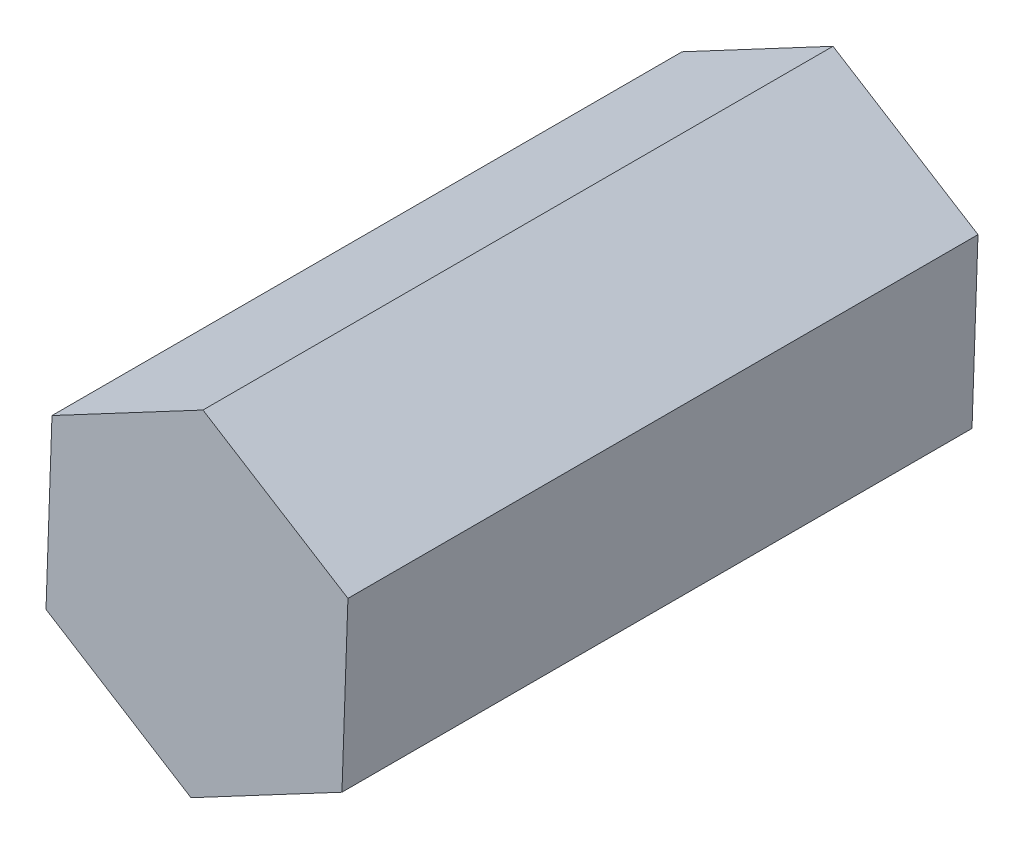
from build123d import *

# Parameters (mm, degrees)
BOSS_EXTRUDE1_DEPTH = 10
SKETCH2_R           = 1.25
CUT_EXTRUDE1_DEPTH  = 5


with BuildPart() as part:
    # Sketch1 → Boss-Extrude1 (new body)
    with BuildSketch(Plane.XY):
        Polygon((2.301082631, -1.438176644), (2.396038824, 1.273707692), (0.094956194, 2.711884337), (-2.301082631, 1.438176644), (-2.396038824, -1.273707692), (-0.094956194, -2.711884337), align=None)
    extrude(amount=BOSS_EXTRUDE1_DEPTH)

    # Sketch2 → Cut-Extrude1 (cut)
    with BuildSketch(Plane.XY):
        Circle(SKETCH2_R)
    extrude(amount=CUT_EXTRUDE1_DEPTH, mode=Mode.SUBTRACT)


solid = part.part
